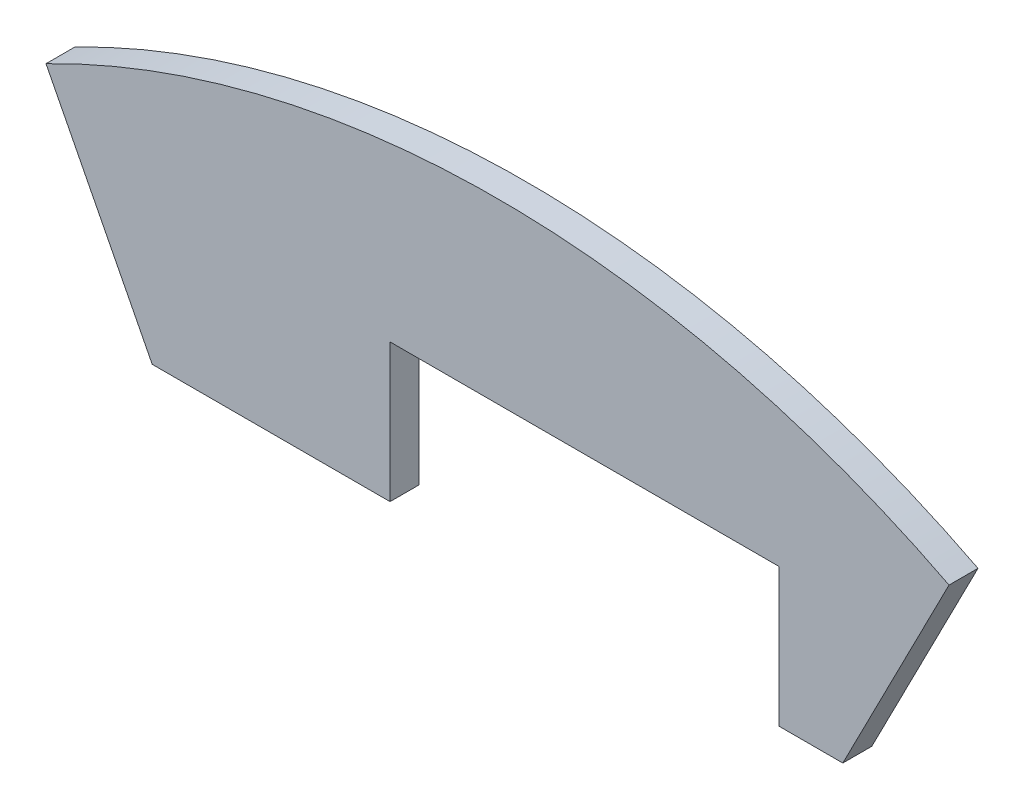
from build123d import *

# Parameters (mm, degrees)
BOSS_EXTRUDE1_DEPTH = 3.175


with BuildPart() as part:
    # Sketch1 → Boss-Extrude1 (new body)
    with BuildSketch(Plane.XY):
        with BuildLine():
            Line((-49.493260593, 96.579937313), (-37.85, 73.859563575))
            Line((-37.85, 73.859563575), (-11.78, 73.859563575))
            Line((-11.78, 73.859563575), (-11.78, 89.024487151))
            Line((-11.78, 89.024487151), (30.85, 89.024487151))
            Line((30.85, 89.024487151), (30.85, 73.859563575))
            Line((30.85, 73.859563575), (37.85, 73.859563575))
            Line((37.85, 73.859563575), (49.493260593, 96.579937313))
            ThreePointArc((49.493260593, 96.579937313), (0, 108.523117977), (-49.493260593, 96.579937313))
        make_face()
    extrude(amount=BOSS_EXTRUDE1_DEPTH)


solid = part.part
